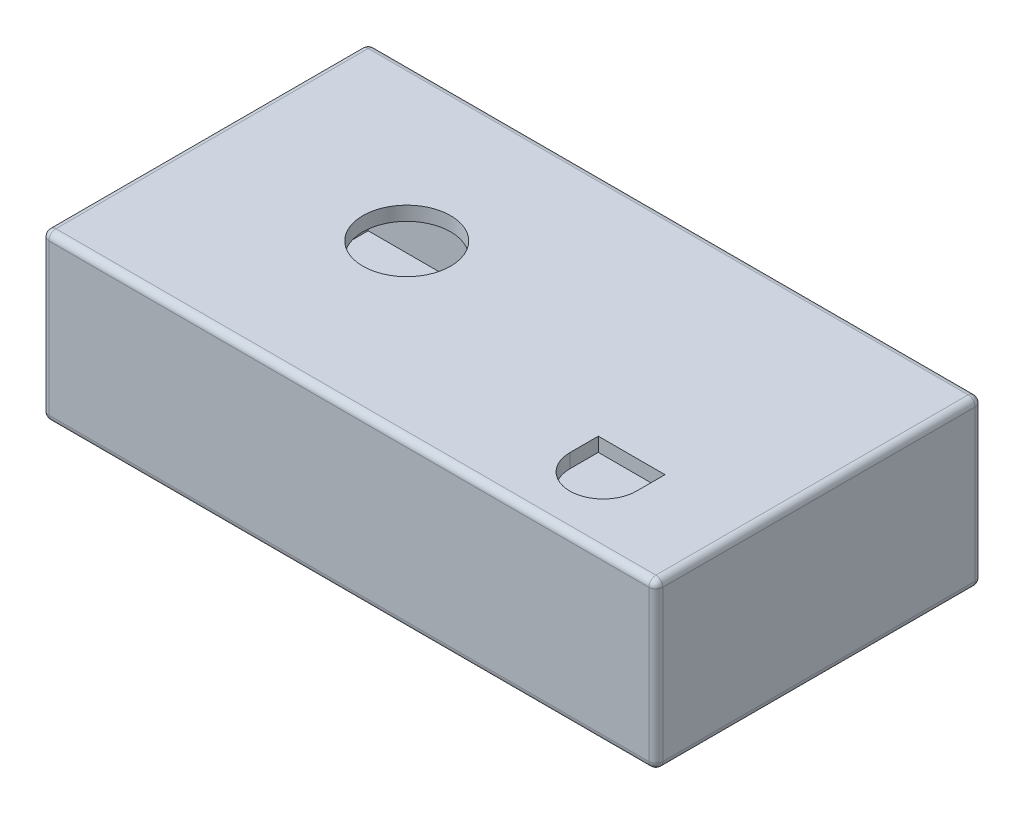
from build123d import *

# Parameters (mm, degrees)
SKETCH1_W           = 222.25
SKETCH1_H           = 59.69
BOSS_EXTRUDE1_DEPTH = 118.11
FILLET1_R           = 2.54
SHELL1_T            = 5.08
SKETCH2_R           = 15.875
CUT_EXTRUDE1_DEPTH  = 7.62


with BuildPart() as part:
    # Sketch1 → Boss-Extrude1 (new body)
    with BuildSketch(Plane.XY):
        with Locations((111.125, 29.845)):
            Rectangle(SKETCH1_W, SKETCH1_H)
    extrude(amount=BOSS_EXTRUDE1_DEPTH)

    # Fillet1
    fillet1_edges = [part.edges().sort_by_distance(p)[0] for p in [
        (222.25, 29.845, 118.11),
        (111.125, 59.69, 118.11),
        (0, 29.845, 118.11),
        (111.125, 59.69, 0),
        (222.25, 29.845, 0),
        (111.125, 0, 0),
        (0, 29.845, 0),
        (111.125, 0, 118.11),
        (0, 59.69, 59.055),
        (222.25, 59.69, 59.055),
        (222.25, 0, 59.055),
        (0, 0, 59.055),
    ]]
    fillet(fillet1_edges, radius=FILLET1_R)

    # Shell1 (no face opened: a closed hollow body)
    add(offset(amount=-SHELL1_T, mode=Mode.PRIVATE), mode=Mode.SUBTRACT)

    # Sketch2 → Cut-Extrude1 (cut)
    with BuildSketch(Plane(origin=(0, 59.69, 0), x_dir=(1, 0, 0), z_dir=(0, 1, 0))):
        with Locations(Location((69.85, -55.88, 0), (0, 0, 270))):  # turned: the seam where the file's is
            Circle(SKETCH2_R)
        with BuildLine():
            Line((165.735, -82.423), (189.865, -82.423))
            Line((189.865, -82.423), (189.865, -92.71))
            ThreePointArc((189.865, -92.71), (177.8, -104.775), (165.735, -92.71))
            Line((165.735, -92.71), (165.735, -82.423))
        make_face()
    extrude(amount=-CUT_EXTRUDE1_DEPTH, mode=Mode.SUBTRACT)


solid = part.part
